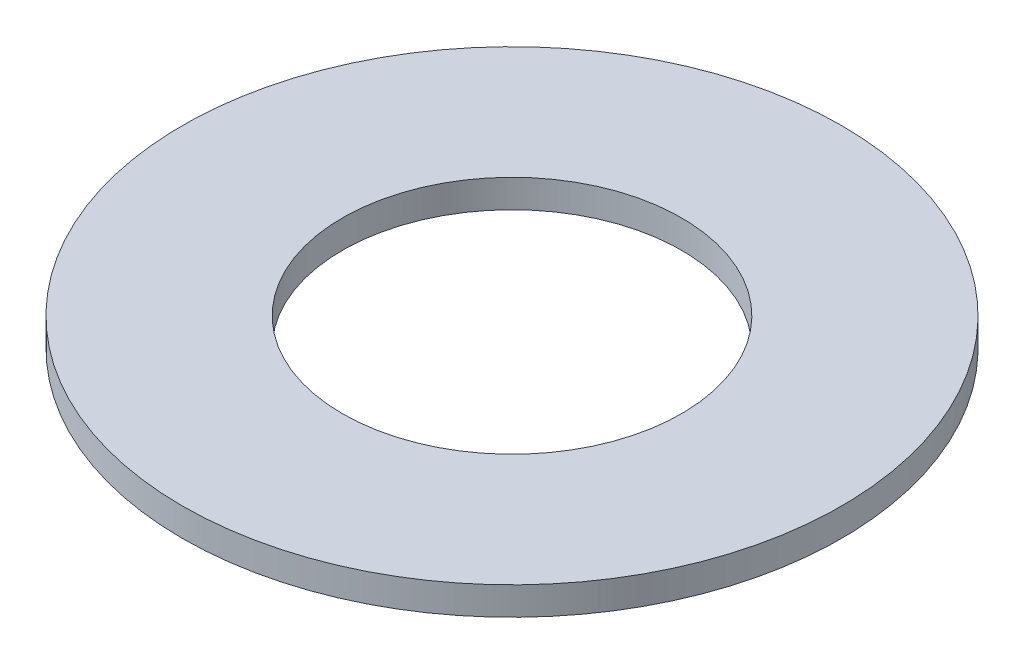
from build123d import *

# Parameters (mm, degrees)
SKETCH1_R           = 4.7625
SKETCH1_R_2         = 2.4511
BOSS_EXTRUDE1_DEPTH = 0.4064


with BuildPart() as part:
    # Sketch1 → Boss-Extrude1 (new body)
    with BuildSketch(Plane(origin=(0, 0, 0), x_dir=(1, 0, 0), z_dir=(0, 1, 0))):
        Circle(SKETCH1_R)
        Circle(SKETCH1_R_2, mode=Mode.SUBTRACT)
    extrude(amount=BOSS_EXTRUDE1_DEPTH)


solid = part.part
